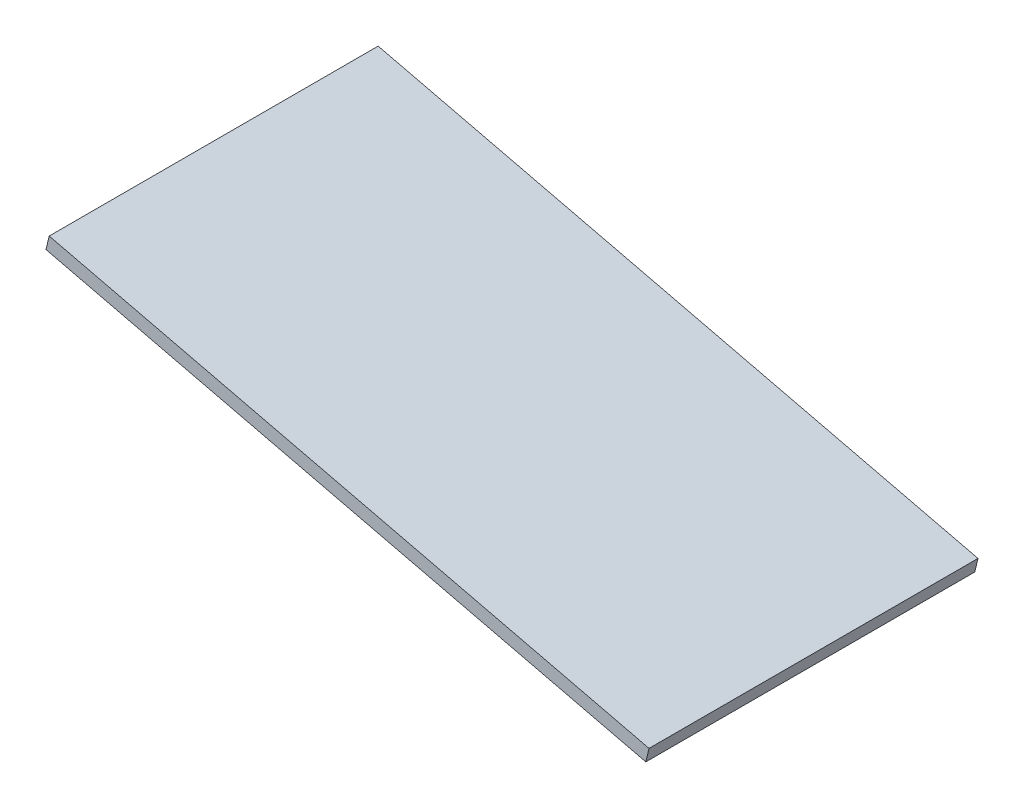
from build123d import *

# Parameters (mm, degrees)
BOSS_EXTRUDE1_DEPTH = 72


with BuildPart() as part:
    # Sketch2 → Boss-Extrude1 (new body)
    with BuildSketch(Plane.XY):
        Polygon((-91.855276303, 555.673613359), (-91.156008729, 558.590979441), (40.125464985, 527.123938597), (39.426197411, 524.206572514), align=None)
    extrude(amount=BOSS_EXTRUDE1_DEPTH)


solid = part.part
